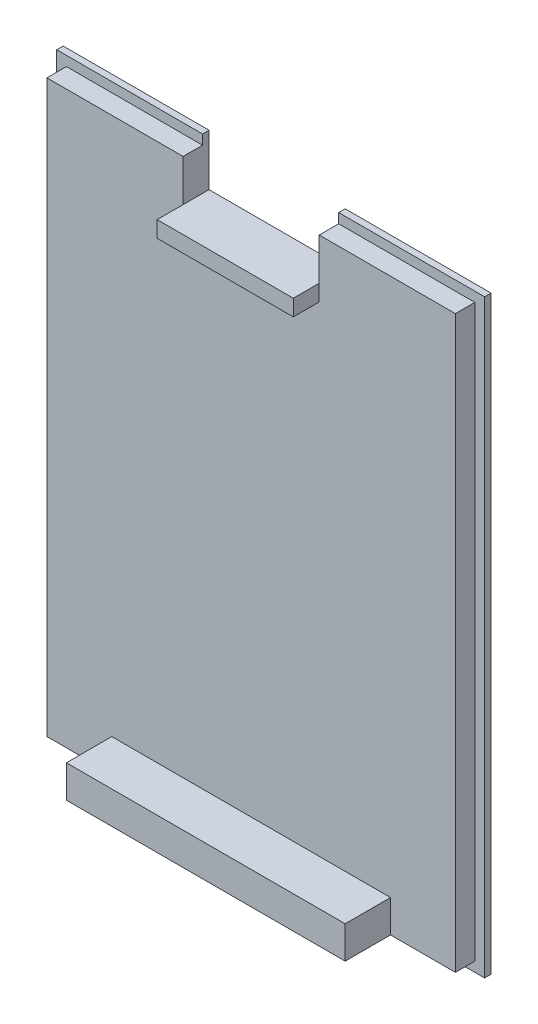
from build123d import *

# Parameters (mm, degrees)
SKETCH1_W                = 32.004
SKETCH1_H                = 44.704
BOSS_EXTRUDE1_DEPTH      = 1.5
BOSS_EXTRUDE1_DEPTH_BACK = 0.0254
SKETCH2_W                = 10.668
SKETCH2_H                = 2.54
BOSS_EXTRUDE2_DEPTH      = 2.032
SKETCH4_W                = 10.668
SKETCH4_H                = 1.746
CUT_EXTRUDE1_DEPTH       = 3.81
SKETCH5_W                = 21.844
SKETCH5_H                = 2.54
BOSS_EXTRUDE3_DEPTH      = 3.556
SKETCH10_W               = 33.528
SKETCH10_H               = 46.228
BOSS_EXTRUDE5_DEPTH      = 0.508
SKETCH13_W               = 10.668
SKETCH13_H               = 5.08
CUT_EXTRUDE2_DEPTH       = 8.128


with BuildPart() as part:
    # Sketch1 → Boss-Extrude1 (new body, two sides)
    with BuildSketch(Plane.XY) as boss_extrude1_sk:
        with Locations((12.794077502, 22.352)):
            Rectangle(SKETCH1_W, SKETCH1_H)
    extrude(amount=BOSS_EXTRUDE1_DEPTH)
    extrude(boss_extrude1_sk.sketch, amount=-BOSS_EXTRUDE1_DEPTH_BACK)

    # Sketch2 → Boss-Extrude2 (add)
    with BuildSketch(Plane.XY.offset(1.5)):
        with Locations((12.794077502, 41.434)):
            Rectangle(SKETCH2_W, SKETCH2_H)
    extrude(amount=BOSS_EXTRUDE2_DEPTH)

    # Sketch4 → Cut-Extrude1 (cut)
    with BuildSketch(Plane.XY.offset(1.5)):
        with Locations((12.794077502, 43.831)):
            Rectangle(SKETCH4_W, SKETCH4_H)
    extrude(amount=-CUT_EXTRUDE1_DEPTH, mode=Mode.SUBTRACT)

    # Sketch5 → Boss-Extrude3 (add)
    with BuildSketch(Plane.XY.offset(1.5)):
        with Locations((12.794077502, 1.27)):
            Rectangle(SKETCH5_W, SKETCH5_H)
    extrude(amount=BOSS_EXTRUDE3_DEPTH)

    # Sketch10 → Boss-Extrude5 (add)
    with BuildSketch(Plane(origin=(0, 0, -0.0254), x_dir=(-1, 0, 0), z_dir=(0, 0, -1))):
        with Locations((-12.794077502, 22.352)):
            Rectangle(SKETCH10_W, SKETCH10_H)
    extrude(amount=BOSS_EXTRUDE5_DEPTH)

    # Sketch13 → Cut-Extrude2 (cut)
    with BuildSketch(Plane.XY.offset(3.532)):
        with Locations((12.794077502, 43.974)):
            Rectangle(SKETCH13_W, SKETCH13_H)
    extrude(amount=-CUT_EXTRUDE2_DEPTH, mode=Mode.SUBTRACT)


solid = part.part
